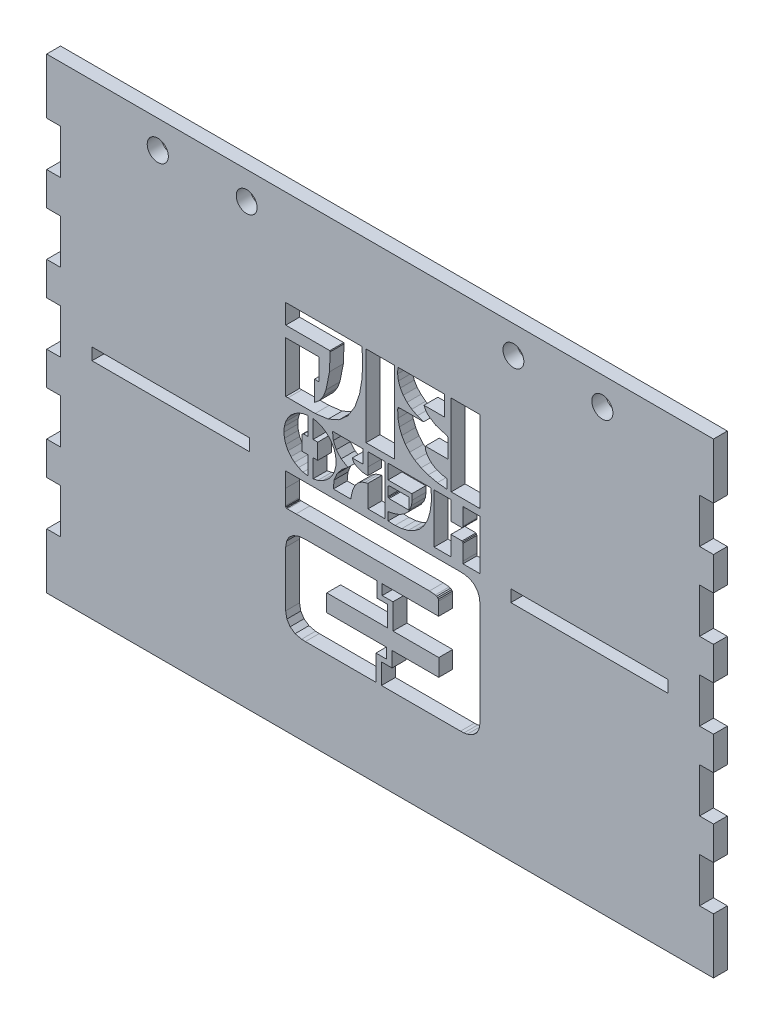
from build123d import *

# Parameters (mm, degrees)
SKETCH1_W               = 152.4
SKETCH1_H               = 106.68
SKETCH1_R               = 2.413
SKETCH1_R_2             = 2.384673294
BOSS_EXTRUDE1_DEPTH     = 3.175
SKETCH2_W               = 3.175
SKETCH2_H               = 10.16
CUT_EXTRUDE1_DEPTH      = 4.175
LPATTERN1_COUNT         = 5
LPATTERN1_PITCH         = 17.78
MIRROR1_COPY_1_SKETCH_W = 3.175
MIRROR1_COPY_1_SKETCH_H = 10.16
MIRROR1_COPY_1_DEPTH    = 4.175
MIRROR1_COPY_2_SKETCH_W = 3.175
MIRROR1_COPY_2_SKETCH_H = 10.16
MIRROR1_COPY_2_DEPTH    = 4.175
MIRROR1_COPY_3_SKETCH_W = 3.175
MIRROR1_COPY_3_SKETCH_H = 10.16
MIRROR1_COPY_3_DEPTH    = 4.175
MIRROR1_COPY_4_SKETCH_W = 3.175
MIRROR1_COPY_4_SKETCH_H = 10.16
MIRROR1_COPY_4_DEPTH    = 4.175
CUT_EXTRUDE2_REACH      = 5.175
SKETCH3_W               = 35.944165261
SKETCH3_H               = 2.7472005
SKETCH3_W_2             = 6.5062989
SKETCH3_H_2             = 18.5750073


with BuildPart() as part:
    # Sketch1 → Boss-Extrude1 (new body)
    with BuildSketch(Plane.XY):
        with Locations((-7.240186916, -0.270980049)):
            Rectangle(SKETCH1_W, SKETCH1_H)
        with Locations((-58.040186916, 46.719019951)):
            Circle(SKETCH1_R, mode=Mode.SUBTRACT)
        with Locations((-37.720186916, 46.719019951)):
            Circle(SKETCH1_R_2, mode=Mode.SUBTRACT)
        with Locations((23.239813084, 46.719019951)):
            Circle(SKETCH1_R_2, mode=Mode.SUBTRACT)
        with Locations((43.559813084, 46.719019951)):
            Circle(SKETCH1_R, mode=Mode.SUBTRACT)
    extrude(amount=BOSS_EXTRUDE1_DEPTH)

    # Sketch2 → Cut-Extrude1 (cut, through all)
    with BuildSketch(Plane.XY.offset(3.175)):
        with Locations((-81.852686916, 35.289019951)):
            Rectangle(SKETCH2_W, SKETCH2_H)
    cut_extrude1 = extrude(amount=-CUT_EXTRUDE1_DEPTH, mode=Mode.SUBTRACT)

    # LPattern1: Cut-Extrude1 ×5
    with Locations(*[(0, -i * LPATTERN1_PITCH, 0) for i in range(1, LPATTERN1_COUNT)]):
        add(cut_extrude1, mode=Mode.SUBTRACT)

    # Mirror1: Cut-Extrude1 across plane
    add(cut_extrude1.mirror(Plane.ZY.offset(7.240186916)), mode=Mode.SUBTRACT)

    # Mirror1 copy 1 sketch → Mirror1 copy 1 (cut, through all)
    with BuildSketch(Plane(origin=(-14.480373832, -17.78, 3.175), x_dir=(-1, 0, 0), z_dir=(0, 0, 1))):
        with Locations((-81.852686916, -35.289019951)):
            Rectangle(MIRROR1_COPY_1_SKETCH_W, MIRROR1_COPY_1_SKETCH_H)
    extrude(amount=-MIRROR1_COPY_1_DEPTH, mode=Mode.SUBTRACT)

    # Mirror1 copy 2 sketch → Mirror1 copy 2 (cut, through all)
    with BuildSketch(Plane(origin=(-14.480373832, -35.56, 3.175), x_dir=(-1, 0, 0), z_dir=(0, 0, 1))):
        with Locations((-81.852686916, -35.289019951)):
            Rectangle(MIRROR1_COPY_2_SKETCH_W, MIRROR1_COPY_2_SKETCH_H)
    extrude(amount=-MIRROR1_COPY_2_DEPTH, mode=Mode.SUBTRACT)

    # Mirror1 copy 3 sketch → Mirror1 copy 3 (cut, through all)
    with BuildSketch(Plane(origin=(-14.480373832, -53.34, 3.175), x_dir=(-1, 0, 0), z_dir=(0, 0, 1))):
        with Locations((-81.852686916, -35.289019951)):
            Rectangle(MIRROR1_COPY_3_SKETCH_W, MIRROR1_COPY_3_SKETCH_H)
    extrude(amount=-MIRROR1_COPY_3_DEPTH, mode=Mode.SUBTRACT)

    # Mirror1 copy 4 sketch → Mirror1 copy 4 (cut, through all)
    with BuildSketch(Plane(origin=(-14.480373832, -71.12, 3.175), x_dir=(-1, 0, 0), z_dir=(0, 0, 1))):
        with Locations((-81.852686916, -35.289019951)):
            Rectangle(MIRROR1_COPY_4_SKETCH_W, MIRROR1_COPY_4_SKETCH_H)
    extrude(amount=-MIRROR1_COPY_4_DEPTH, mode=Mode.SUBTRACT)

    # Sketch3 → Cut-Extrude2 (cut, up to next)
    with BuildSketch(Plane(origin=(0, 0.458195707, 0), x_dir=(-1, 0, 0), z_dir=(0, 0, -1)), mode=Mode.PRIVATE) as cut_extrude2_sk1:
        Polygon((5.721162072, -25.955737601), (19.422645972, -25.955737601), (19.422645972, -22.027932401), (5.562399372, -22.027932401), (5.529480972, -17.348604701), (7.990131372, -17.348604701), (7.975843872, -13.880857001), (24.465561972, -13.883371601), (25.857621672, -14.035276301), (27.097319472, -14.519565401), (28.019949072, -15.299777201), (28.599221472, -16.354537601), (28.806904572, -17.667387401), (28.807476072, -30.294759911), (28.535213472, -31.771241591), (27.793063572, -32.931478031), (26.649492072, -33.719039321), (25.172507472, -34.080558791), (24.310456872, -34.111568381), (8.204100972, -34.112802821), (8.181812472, -28.322159081), (5.721162072, -28.322159081), align=None)
    cut_extrude2_tool1 = extrude(cut_extrude2_sk1.sketch, amount=-CUT_EXTRUDE2_REACH, mode=Mode.PRIVATE) & part.part
    add(cut_extrude2_tool1.solids().sort_by_distance((-12.571904, -25.805957, 0))[0], mode=Mode.SUBTRACT)
    # Sketch3 → Cut-Extrude2 (cut, up to next)
    with BuildSketch(Plane(origin=(0, 0.458195707, 0), x_dir=(-1, 0, 0), z_dir=(0, 0, -1)), mode=Mode.PRIVATE) as cut_extrude2_sk2:
        Polygon((4.276295772, -22.027932401), (-6.181354128, -22.027932401), (-6.181354128, -25.955737601), (4.485921972, -25.955737601), (4.490836872, -29.433406541), (6.951487272, -29.433406541), (6.917997372, -34.112802821), (-11.165222748, -34.106619191), (-11.935399008, -34.068168671), (-12.692556498, -33.941032781), (-13.926607878, -33.442467611), (-14.832595398, -32.636321141), (-15.396277278, -31.541795771), (-15.602783088, -30.178173911), (-15.603400308, -25.454074901), (-15.605880618, -7.012341401), (-15.478127508, -5.525412701), (-15.042804528, -4.399214801), (-14.291853528, -3.520476401), (-13.268034138, -2.920287101), (-12.014163138, -2.628822101), (-11.107558398, -2.583559301), (28.137792372, -2.582302001), (28.821763572, -2.582302001), (28.821763572, -6.026389601), (28.828621572, -9.478135301), (28.809419172, -9.691304801), (28.737524472, -9.828464801), (28.600935972, -9.898416401), (28.389480972, -9.913961201), (26.436208272, -9.907217501), (-4.042572528, -9.911446601), (-5.393827128, -10.029289901), (-5.696379228, -10.127245001), (-5.932637328, -10.300866701), (-6.088313928, -10.549012001), (-6.147178428, -10.870195001), (-6.152207628, -13.884514601), (-5.649859128, -13.884514601), (6.772264872, -13.881542801), (6.759234672, -16.236694301), (4.299270072, -16.237380101), align=None)
    cut_extrude2_tool2 = extrude(cut_extrude2_sk2.sketch, amount=-CUT_EXTRUDE2_REACH, mode=Mode.PRIVATE) & part.part
    add(cut_extrude2_tool2.solids().sort_by_distance((0.396515, -15.188944, 0))[0], mode=Mode.SUBTRACT)
    # Sketch3 → Cut-Extrude2 (cut, up to next)
    with BuildSketch(Plane(origin=(0, 0.458195707, 0), x_dir=(-1, 0, 0), z_dir=(0, 0, -1)), mode=Mode.PRIVATE) as cut_extrude2_sk3:
        Polygon((-9.017708628, 30.764380099), (-9.017708628, 12.172684999), (-15.216449088, 12.166512799), (-15.574253808, 12.185715199), (-15.574253808, 30.764380099), align=None)
    cut_extrude2_tool3 = extrude(cut_extrude2_sk3.sketch, amount=-CUT_EXTRUDE2_REACH, mode=Mode.PRIVATE) & part.part
    add(cut_extrude2_tool3.solids().sort_by_distance((12.296082, 21.925363, 0))[0], mode=Mode.SUBTRACT)
    # Sketch3 → Cut-Extrude2 (cut, up to next)
    with BuildSketch(Plane(origin=(0, 0.458195707, 0), x_dir=(-1, 0, 0), z_dir=(0, 0, -1)), mode=Mode.PRIVATE) as cut_extrude2_sk4:
        Polygon((-8.005696428, 14.364273199), (-7.061235528, 14.488288699), (-6.152779128, 14.750492899), (-5.310045228, 15.135569599), (-4.562866128, 15.624887899), (-3.940274028, 16.201645699), (-3.471415428, 16.848355099), (-3.186122628, 17.547985399), (-3.112970628, 18.282248599), (-8.282873928, 18.282248599), (-8.282873928, 22.001570599), (-8.269843728, 22.492717699), (-8.180003928, 22.756864999), (-7.936887828, 22.892767699), (-7.465628928, 22.997580799), (-5.453948928, 23.602684999), (-3.705730428, 24.767973499), (-3.162691128, 25.425312799), (-2.796702528, 26.214668599), (-7.474887228, 26.214668599), (-7.475573028, 30.764380099), (3.160613472, 30.764380099), (3.227707572, 29.405238799), (3.036712272, 28.115934799), (2.602029372, 26.915327599), (1.938403572, 25.821590899), (1.061608272, 24.853469899), (-0.014869128, 24.029481199), (-1.275598128, 23.367798499), (-2.706291228, 22.886481199), (-2.244747828, 22.886481199), (2.658379272, 22.895853799), (2.921383572, 22.871622199), (3.088147272, 22.779953599), (3.178101372, 22.612389799), (3.211019772, 22.356814999), (3.143354172, 20.678890999), (2.829714972, 19.118695999), (2.277074472, 17.688002899), (1.495033872, 16.398813199), (0.491708472, 15.263471299), (-0.723643428, 14.293635799), (-2.143135128, 13.501651099), (-3.757394028, 12.898832899), (-5.864400228, 12.425173699), (-8.005696428, 12.203203099), align=None)
    cut_extrude2_tool4 = extrude(cut_extrude2_sk4.sketch, amount=-CUT_EXTRUDE2_REACH, mode=Mode.PRIVATE) & part.part
    add(cut_extrude2_tool4.solids().sort_by_distance((2.470807, 22.893782, 0))[0], mode=Mode.SUBTRACT)
    # Sketch3 → Cut-Extrude2 (cut, up to next)
    with BuildSketch(Plane(origin=(0, 0.458195707, 0), x_dir=(-1, 0, 0), z_dir=(0, 0, -1)), mode=Mode.PRIVATE) as cut_extrude2_sk5:
        with Locations((-40.624183475, -1.546686851)):
            Rectangle(SKETCH3_W, SKETCH3_H)
    cut_extrude2_tool5 = extrude(cut_extrude2_sk5.sketch, amount=-CUT_EXTRUDE2_REACH, mode=Mode.PRIVATE) & part.part
    add(cut_extrude2_tool5.solids().sort_by_distance((40.624183, -1.088491, 0))[0], mode=Mode.SUBTRACT)
    # Sketch3 → Cut-Extrude2 (cut, up to next)
    with BuildSketch(Plane(origin=(0, 0.458195707, 0), x_dir=(-1, 0, 0), z_dir=(0, 0, -1)), mode=Mode.PRIVATE) as cut_extrude2_sk6:
        Polygon((28.800046572, 23.779392799), (28.800046572, 12.151653799), (28.281124572, 12.151653799), (22.060689972, 12.155997199), (19.093461972, 12.531815599), (16.597378572, 13.638811099), (14.565924672, 15.466125199), (12.992013672, 18.001184899), (11.928566472, 21.060310099), (11.386555872, 24.251337499), (11.206761972, 27.376185199), (11.357409372, 30.504004699), (11.397757272, 30.759465199), (28.793188572, 30.759465199), (28.793188572, 26.267360899), (18.718100772, 26.267360899), (18.646206072, 26.058991999), (18.806226072, 22.029459799), (19.585752072, 18.073765399), (20.175540072, 16.553918299), (21.097026672, 15.208835899), (21.617205972, 14.745577999), (22.239912372, 14.254430899), (22.239912372, 18.863806999), (21.188123772, 18.863806999), (21.188123772, 23.779392799), align=None)
    cut_extrude2_tool6 = extrude(cut_extrude2_sk6.sketch, amount=-CUT_EXTRUDE2_REACH, mode=Mode.PRIVATE) & part.part
    add(cut_extrude2_tool6.solids().sort_by_distance((-28.543966, 18.423719, 0))[0], mode=Mode.SUBTRACT)
    # Sketch3 → Cut-Extrude2 (cut, up to next)
    with BuildSketch(Plane(origin=(0, 0.458195707, 0), x_dir=(-1, 0, 0), z_dir=(0, 0, -1)), mode=Mode.PRIVATE) as cut_extrude2_sk7:
        with Locations((7.190202822, 21.465789349)):
            Rectangle(SKETCH3_W_2, SKETCH3_H_2)
    cut_extrude2_tool7 = extrude(cut_extrude2_sk7.sketch, amount=-CUT_EXTRUDE2_REACH, mode=Mode.PRIVATE) & part.part
    add(cut_extrude2_tool7.solids().sort_by_distance((-7.190203, 21.923985, 0))[0], mode=Mode.SUBTRACT)
    # Sketch3 → Cut-Extrude2 (cut, up to next)
    with BuildSketch(Plane(origin=(0, 0.458195707, 0), x_dir=(-1, 0, 0), z_dir=(0, 0, -1)), mode=Mode.PRIVATE) as cut_extrude2_sk8:
        Polygon((10.028557572, 7.580110999), (10.028557572, 5.851323499), (11.257511172, 5.952936199), (12.387480972, 6.293435899), (13.229529072, 6.845390599), (13.596774972, 7.580110999), (11.094519372, 7.580110999), (11.081489172, 10.619347999), (18.108767472, 10.619347999), (17.915143272, 8.887360099), (17.244773772, 7.381686199), (16.123719372, 6.144617299), (14.580212172, 5.219930299), (16.010790972, 4.071558199), (17.087268372, 2.725789999), (17.744721972, 1.143420799), (17.920743972, -0.717040301), (13.947104472, -0.717040301), (13.754166072, 0.215076199), (13.527166272, 1.131533599), (13.199811072, 1.990498099), (12.750269172, 2.759279899), (12.149394072, 3.410446999), (11.368039272, 3.914738599), (10.732416972, 4.146653299), (10.014841572, 4.358108299), (10.014841572, -0.713382701), (6.136071072, -0.713382701), (6.136071072, 10.619347999), (10.032786672, 10.619347999), align=None)
    cut_extrude2_tool8 = extrude(cut_extrude2_sk8.sketch, amount=-CUT_EXTRUDE2_REACH, mode=Mode.PRIVATE) & part.part
    add(cut_extrude2_tool8.solids().sort_by_distance((-11.667355, 5.729419, 0))[0], mode=Mode.SUBTRACT)
    # Sketch3 → Cut-Extrude2 (cut, up to next)
    with BuildSketch(Plane(origin=(0, 0.458195707, 0), x_dir=(-1, 0, 0), z_dir=(0, 0, -1)), mode=Mode.PRIVATE) as cut_extrude2_sk9:
        Polygon((22.535034972, 6.775896199), (22.362556272, 6.775896199), (21.480274572, 6.775896199), (21.480274572, 3.161730199), (22.535034972, 3.161730199), (22.534349172, -1.001647301), (21.445527372, -0.764131901), (20.441516172, -0.338021501), (19.541175072, 0.256567099), (18.764620872, 0.999402799), (18.130941672, 1.870825999), (17.659568472, 2.850605599), (17.370732372, 3.918396199), (17.282607072, 5.054309599), (17.403536472, 6.158790499), (17.717404272, 7.195148599), (18.202836372, 8.144410099), (18.841659072, 8.987829799), (19.613641272, 9.705290899), (20.499809172, 10.278848299), (21.479588772, 10.688270899), (22.535034972, 10.914470599), align=None)
    cut_extrude2_tool9 = extrude(cut_extrude2_sk9.sketch, amount=-CUT_EXTRUDE2_REACH, mode=Mode.PRIVATE) & part.part
    add(cut_extrude2_tool9.solids().sort_by_distance((-20.188045, 5.411467, 0))[0], mode=Mode.SUBTRACT)
    # Sketch3 → Cut-Extrude2 (cut, up to next)
    with BuildSketch(Plane(origin=(0, 0.458195707, 0), x_dir=(-1, 0, 0), z_dir=(0, 0, -1)), mode=Mode.PRIVATE) as cut_extrude2_sk10:
        Polygon((23.725583772, 3.161730199), (25.062550872, 3.161730199), (25.047234672, 6.536437699), (24.925619472, 6.680227099), (24.717136272, 6.764694799), (23.725583772, 6.777724999), (23.725583772, 10.933672999), (24.863554572, 10.730333299), (25.912828572, 10.327882999), (26.852374572, 9.745638799), (27.663447372, 9.005774899), (28.325130072, 8.127722299), (28.818105972, 7.132397899), (29.122029672, 6.040375699), (29.216784372, 4.871429599), (29.094026172, 3.724886299), (28.770328572, 2.655838399), (28.266151272, 1.684745599), (27.600810972, 0.830810299), (26.794081572, 0.112663399), (25.866308472, -0.449235401), (24.836808372, -0.835455101), (23.725583772, -1.027707701), align=None)
    cut_extrude2_tool10 = extrude(cut_extrude2_sk10.sketch, amount=-CUT_EXTRUDE2_REACH, mode=Mode.PRIVATE) & part.part
    add(cut_extrude2_tool10.solids().sort_by_distance((-26.209929, 5.409406, 0))[0], mode=Mode.SUBTRACT)
    # Sketch3 → Cut-Extrude2 (cut, up to next)
    with BuildSketch(Plane(origin=(0, 0.458195707, 0), x_dir=(-1, 0, 0), z_dir=(0, 0, -1)), mode=Mode.PRIVATE) as cut_extrude2_sk11:
        Polygon((-11.724572658, -0.724469801), (-15.582323388, -0.724469801), (-15.582323388, 10.632949699), (-11.760542868, 10.632949699), (-11.725807098, 10.106598199), (-11.730756288, 6.790755199), (-11.714639988, 6.570613399), (-11.645808528, 6.419965999), (-11.506282518, 6.335612599), (-11.276848128, 6.314467099), (-8.991648228, 6.322010899), (-8.991648228, 10.628034799), (-5.109791628, 10.628034799), (-5.109791628, -0.710753801), (-8.966273628, -0.710753801), (-8.966273628, 3.731629999), (-11.499458808, 3.714370699), (-11.635887288, 3.569209699), (-11.714639988, 3.323693299), (-11.724572658, -0.173086601), align=None)
    cut_extrude2_tool11 = extrude(cut_extrude2_sk11.sketch, amount=-CUT_EXTRUDE2_REACH, mode=Mode.PRIVATE) & part.part
    add(cut_extrude2_tool11.solids().sort_by_distance((10.347991, 5.421897, 0))[0], mode=Mode.SUBTRACT)
    # Sketch3 → Cut-Extrude2 (cut, up to next)
    with BuildSketch(Plane(origin=(0, 0.458195707, 0), x_dir=(-1, 0, 0), z_dir=(0, 0, -1)), mode=Mode.PRIVATE) as cut_extrude2_sk12:
        Polygon((-0.029156628, 7.314134899), (-0.101622828, 6.077065999), (0.050281872, 4.959554899), (0.421756872, 3.968459599), (1.008344472, 3.107894899), (1.804443972, 2.382889999), (2.806054872, 1.798245499), (4.007119272, 1.358533399), (5.404322472, 1.069582999), (5.404322472, -0.792706901), (3.816123972, -0.873859901), (2.274559872, -0.740014601), (0.812891472, -0.372197201), (-0.537563028, 0.249823399), (-1.743085128, 1.145135299), (-2.772013728, 2.332712299), (-3.590516028, 3.833356999), (-4.166016528, 5.665243099), (-4.487771028, 7.977532099), (-4.447423128, 10.312909699), (-4.361812428, 10.578428599), (-4.097093628, 10.663353499), (5.213327172, 10.655809699), (5.411751972, 10.613175799), (5.411751972, 7.314134899), align=None)
    cut_extrude2_tool12 = extrude(cut_extrude2_sk12.sketch, amount=-CUT_EXTRUDE2_REACH, mode=Mode.PRIVATE) & part.part
    add(cut_extrude2_tool12.solids().sort_by_distance((0.217152, 7.162686, 0))[0], mode=Mode.SUBTRACT)
    # Sketch3 → Cut-Extrude2 (cut, up to next)
    with BuildSketch(Plane(origin=(0, 0.458195707, 0), x_dir=(-1, 0, 0), z_dir=(0, 0, -1)), mode=Mode.PRIVATE) as cut_extrude2_sk13:
        Polygon((0.663501372, 6.319496299), (5.153776872, 6.306466099), (5.326827072, 6.200967199), (5.430268572, 6.018772999), (5.430954372, 4.022523499), (5.336656872, 3.851987899), (5.177894172, 3.752089699), (0.663501372, 3.740431099), align=None)
    cut_extrude2_tool13 = extrude(cut_extrude2_sk13.sketch, amount=-CUT_EXTRUDE2_REACH, mode=Mode.PRIVATE) & part.part
    add(cut_extrude2_tool13.solids().sort_by_distance((-3.032636, 5.487358, 0))[0], mode=Mode.SUBTRACT)
    # Sketch3 → Cut-Extrude2 (cut, up to next)
    with BuildSketch(Plane(origin=(0, 0.458195707, 0), x_dir=(-1, 0, 0), z_dir=(0, 0, -1)), mode=Mode.PRIVATE) as cut_extrude2_sk14:
        with Locations((55.104557307, -1.546686851)):
            Rectangle(SKETCH3_W, SKETCH3_H)
    cut_extrude2_tool14 = extrude(cut_extrude2_sk14.sketch, amount=-CUT_EXTRUDE2_REACH, mode=Mode.PRIVATE) & part.part
    add(cut_extrude2_tool14.solids().sort_by_distance((-55.104557, -1.088491, 0))[0], mode=Mode.SUBTRACT)


solid = part.part
